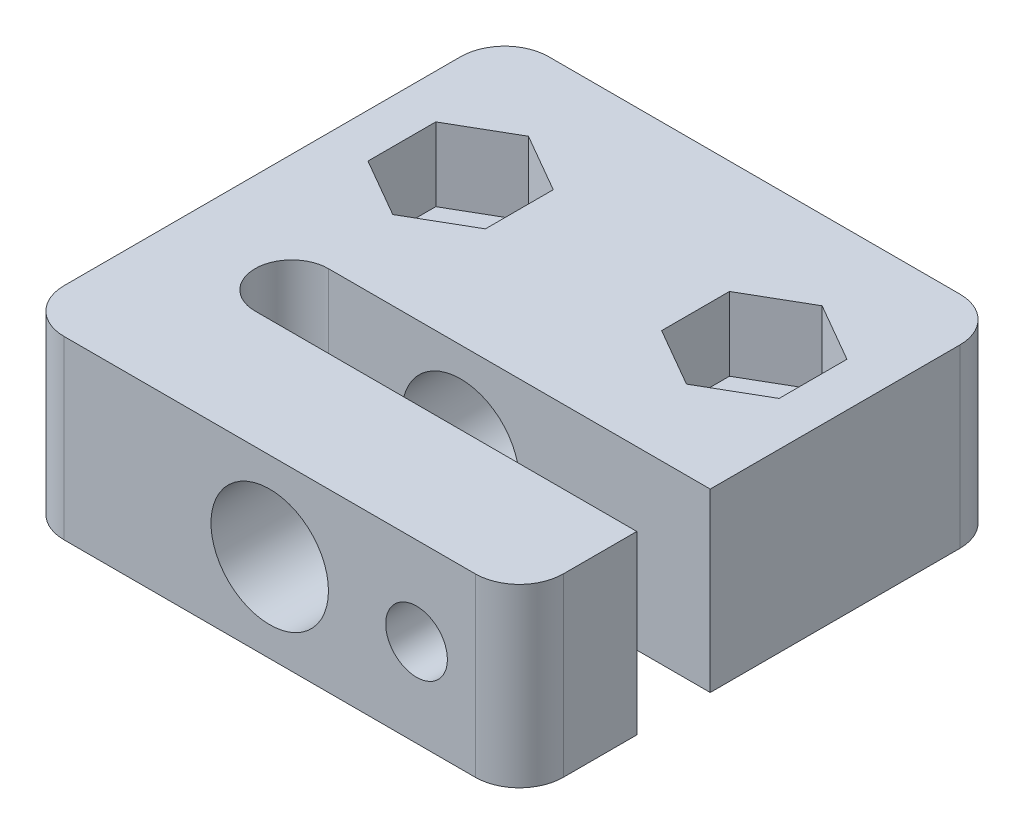
from build123d import *

# Parameters (mm, degrees)
SKETCH1_W                 = 34
SKETCH1_H                 = 12
BOSS_EXTRUDE1_DEPTH       = 33
SKETCH2_R                 = 4
CUT_EXTRUDE1_DEPTH        = 34
SKETCH3_R                 = 2.55
CUT_EXTRUDE2_DEPTH        = 13
CUT_EXTRUDE3_DEPTH        = 5
SKETCH5_R                 = 4.5
CUT_EXTRUDE4_DEPTH        = 2
CUT_EXTRUDE5_DEPTH        = 13
M5X0_8_TAPPED_HOLE1_D     = 4.2
M5X0_8_TAPPED_HOLE1_DEPTH = 8
FILLET1_R                 = 3


with BuildPart() as part:
    # Sketch1 → Boss-Extrude1 (new body)
    with BuildSketch(Plane.XY):
        Rectangle(SKETCH1_W, SKETCH1_H)
    extrude(amount=BOSS_EXTRUDE1_DEPTH)

    # Sketch2 → Cut-Extrude1 (cut, through all)
    with BuildSketch(Plane.XY.offset(33)):
        Circle(SKETCH2_R)
    extrude(amount=-CUT_EXTRUDE1_DEPTH, mode=Mode.SUBTRACT)

    # Sketch3 → Cut-Extrude2 (cut, through all)
    with BuildSketch(Plane(origin=(0, 6, 0), x_dir=(1, 0, 0), z_dir=(0, 1, 0))):
        with Locations((-10, -10)):
            Circle(SKETCH3_R)
        with Locations((10, -10)):
            Circle(SKETCH3_R)
    extrude(amount=-CUT_EXTRUDE2_DEPTH, mode=Mode.SUBTRACT)

    # Sketch4 → Cut-Extrude3 (cut)
    with BuildSketch(Plane(origin=(0, 6, 0), x_dir=(1, 0, 0), z_dir=(0, 1, 0))):
        Polygon((-10, -5.381197846), (-14, -7.690598923), (-14, -12.309401077), (-10, -14.618802154), (-6, -12.309401077), (-6, -7.690598923), align=None)
        Polygon((6, -7.690598923), (10, -5.381197846), (14, -7.690598923), (14, -12.309401077), (10, -14.618802154), (6, -12.309401077), align=None)
    extrude(amount=-CUT_EXTRUDE3_DEPTH, mode=Mode.SUBTRACT)

    # Sketch5 → Cut-Extrude4 (cut)
    with BuildSketch(Plane.XZ.offset(6)):
        with Locations((10, 10)):
            Circle(SKETCH5_R)
        with Locations((-10, 10)):
            Circle(SKETCH5_R)
    extrude(amount=-CUT_EXTRUDE4_DEPTH, mode=Mode.SUBTRACT)

    # Sketch6 → Cut-Extrude5 (cut, through all)
    with BuildSketch(Plane(origin=(0, 6, 0), x_dir=(1, 0, 0), z_dir=(0, 1, 0))):
        with BuildLine():
            Line((17, -25), (-9, -25))
            ThreePointArc((-9, -25), (-11.5, -22.5), (-9, -20))
            Line((-9, -20), (17, -20))
            ThreePointArc((17, -20), (19.5, -22.5), (17, -25))
        make_face()
    extrude(amount=-CUT_EXTRUDE5_DEPTH, mode=Mode.SUBTRACT)

    # M5x0.8 Tapped Hole1
    with Locations(Plane.XY.offset(33)):
        with Locations((10, 0)):
            Hole(M5X0_8_TAPPED_HOLE1_D / 2, depth=M5X0_8_TAPPED_HOLE1_DEPTH)

    # Fillet1
    fillet1_edges = [part.edges().sort_by_distance(p)[0] for p in [
        (17, 0, 33),
        (-17, 0, 33),
        (17, 0, 0),
        (-17, 0, 0),
    ]]
    fillet(fillet1_edges, radius=FILLET1_R)


solid = part.part
